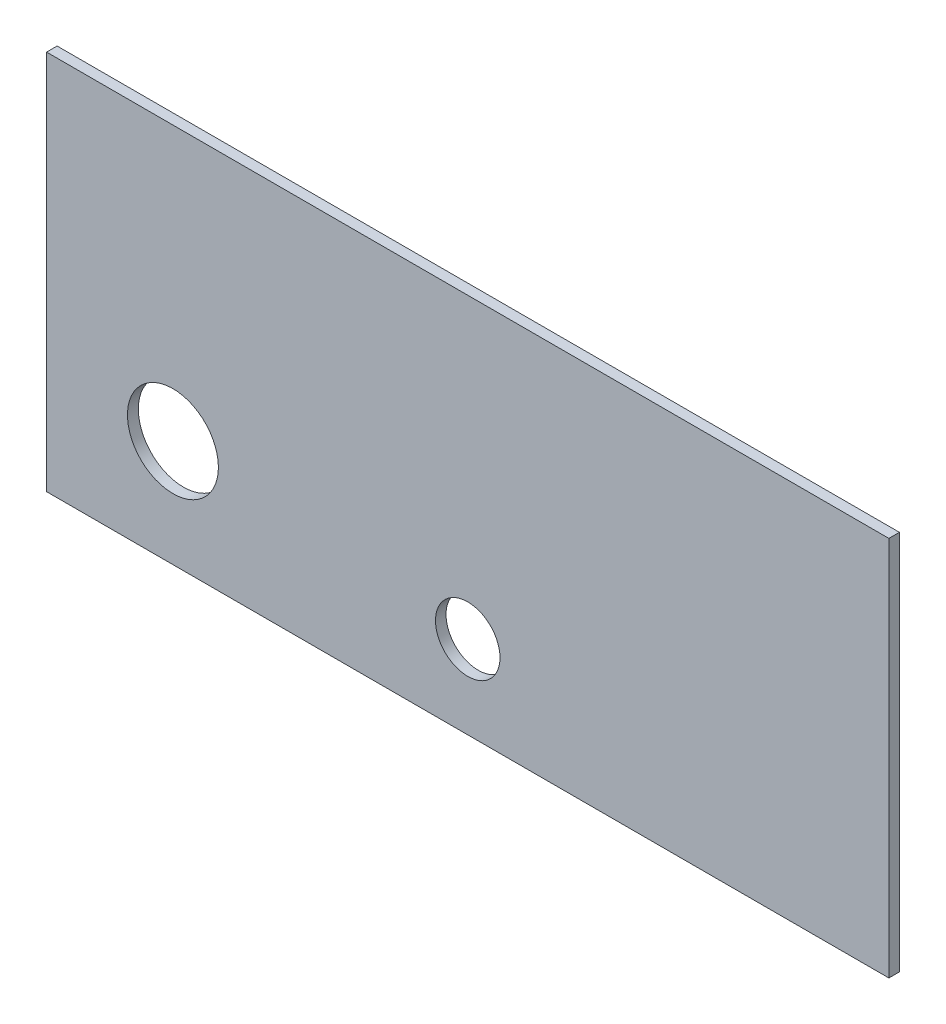
from build123d import *

# Parameters (mm, degrees)
SKETCH2_W           = 127
SKETCH2_H           = 57.404
SKETCH2_R           = 4.864
BOSS_EXTRUDE1_DEPTH = 1.5875


with BuildPart() as part:
    # Sketch2 → Boss-Extrude1 (new body)
    with BuildSketch(Plane.XY):
        with Locations((63.5, 28.702)):
            Rectangle(SKETCH2_W, SKETCH2_H)
        with Locations((63.5, 12.500102)):
            Circle(SKETCH2_R, mode=Mode.SUBTRACT)
    extrude(amount=-BOSS_EXTRUDE1_DEPTH)

    # Sketch3 → 1/4 NPT Tapped Hole1 (revolve, cut)
    with BuildSketch(Plane(origin=(19.05, 16.129, 0), x_dir=(0, -1, 0), z_dir=(1, 0, 0))):
        Polygon((0, 0), (0, 1.5875), (5.5626, 1.5875), (5.5626, 9.906), (6.557984794, 9.906), (6.8545837, 0), align=None)
    revolve(axis=Axis((19.05, 16.129, 6.35), (0, 0, -1)), mode=Mode.SUBTRACT)


solid = part.part
